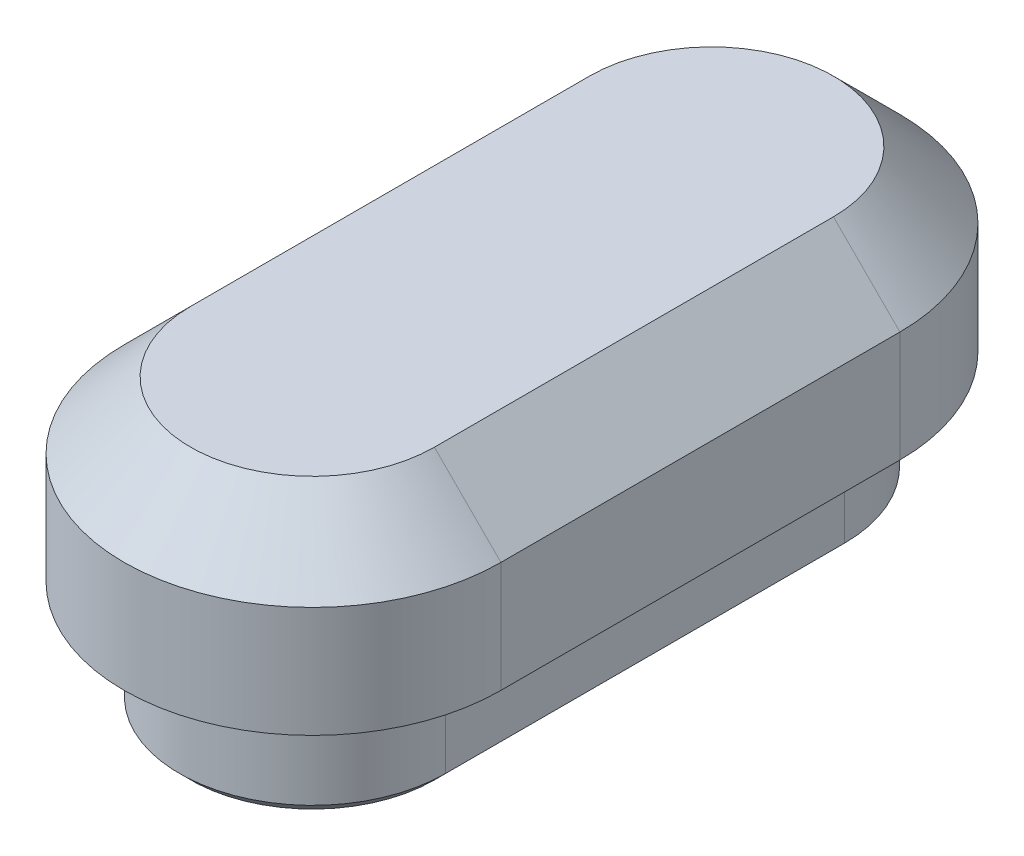
from build123d import *

# Parameters (mm, degrees)
EXTRUSION1_DEPTH = 8
CHANFREIN1_SIZE  = 3
COQUE1_T         = -4
EXTRUSION2_DEPTH = 5
CHANFREIN2_SIZE  = 0.5


with BuildPart() as part:
    # Esquisse1 → Extrusion1 (new body)
    with BuildSketch(Plane(origin=(0, 0, 0), x_dir=(1, 0, 0), z_dir=(0, 1, 0))):
        with BuildLine():
            Line((-8.5, 9), (-8.5, -9))
            ThreePointArc((-8.5, -9), (0, -17.5), (8.5, -9))
            Line((8.5, -9), (8.5, 9))
            ThreePointArc((8.5, 9), (0, 17.5), (-8.5, 9))
        make_face()
    extrude(amount=EXTRUSION1_DEPTH)

    # Chanfrein1
    chanfrein1_edges = [part.edges().sort_by_distance(p)[0] for p in [
        (0, 8, 17.5),
        (8.5, 8, 0),
        (0, 8, -17.5),
        (-8.5, 8, 0),
    ]]
    chamfer(chanfrein1_edges, length=CHANFREIN1_SIZE)

    # Coque1
    coque1_openings = [part.faces().sort_by_distance(p)[0] for p in [
        (0, 0, 0),
    ]]
    offset(amount=COQUE1_T, openings=coque1_openings, kind=Kind.INTERSECTION)

    # Esquisse2 → Extrusion2 (add)
    with BuildSketch(Plane.XZ):
        with BuildLine():
            Line((-6, -9), (-6, 9))
            ThreePointArc((-6, 9), (0, 15), (6, 9))
            Line((6, 9), (6, -9))
            ThreePointArc((6, -9), (0, -15), (-6, -9))
        make_face()
        with BuildLine():
            Line((4.5, 9), (4.5, -9))
            ThreePointArc((4.5, -9), (0, -13.5), (-4.5, -9))
            Line((-4.5, -9), (-4.5, 9))
            ThreePointArc((-4.5, 9), (0, 13.5), (4.5, 9))
        make_face(mode=Mode.SUBTRACT)
    extrude(amount=EXTRUSION2_DEPTH)

    # Chanfrein2
    chanfrein2_edges = [part.edges().sort_by_distance(p)[0] for p in [
        (0, -5, -15),
        (6, -5, 0),
        (0, -5, 15),
        (-6, -5, 0),
    ]]
    chamfer(chanfrein2_edges, length=CHANFREIN2_SIZE)


solid = part.part
